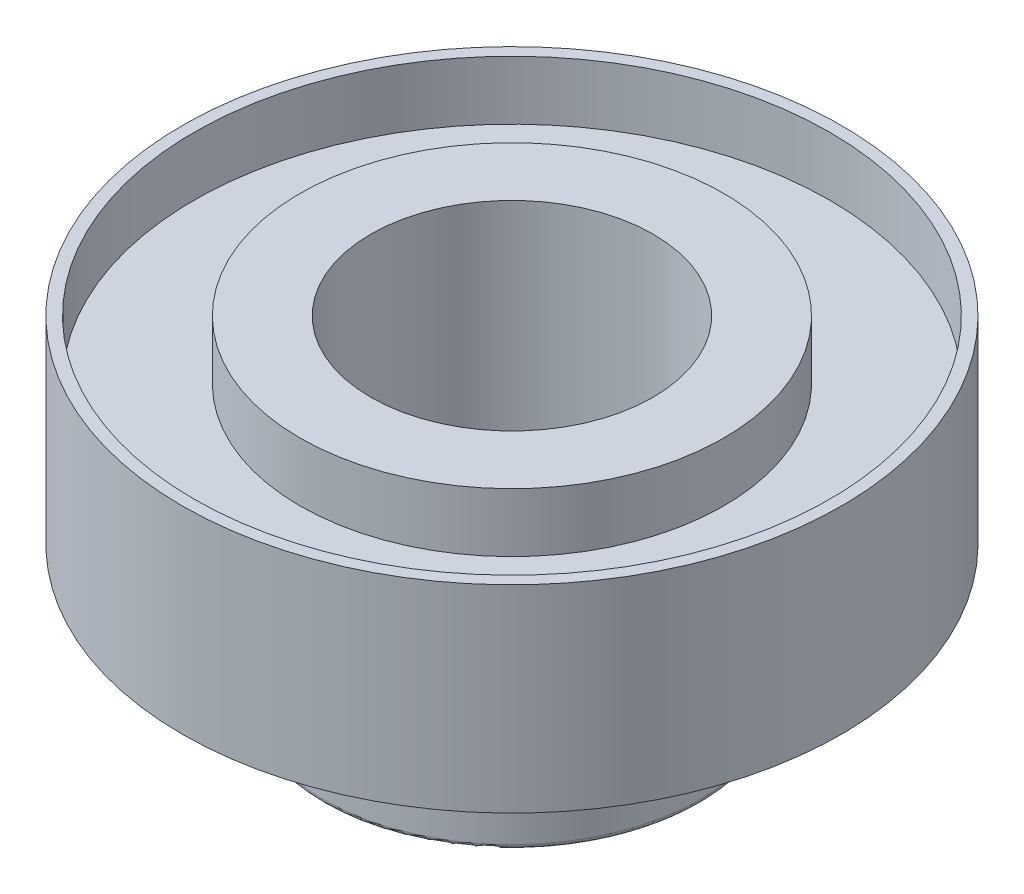
from build123d import *

# Parameters (mm, degrees)
SKETCH1_R           = 7
BOSS_EXTRUDE1_DEPTH = 4.2
SKETCH2_R           = 3
CUT_EXTRUDE1_DEPTH  = 4.2
SKETCH3_R           = 6.75
SKETCH3_R_2         = 4.5
CUT_EXTRUDE2_DEPTH  = 1.25
SKETCH4_R           = 4
SKETCH4_R_2         = 3
BOSS_EXTRUDE2_DEPTH = 2.8
FILLET1_R           = 0.1


with BuildPart() as part:
    # Sketch1 → Boss-Extrude1 (new body)
    with BuildSketch(Plane(origin=(0, 0, 0), x_dir=(1, 0, 0), z_dir=(0, 1, 0))):
        Circle(SKETCH1_R)
    extrude(amount=BOSS_EXTRUDE1_DEPTH)

    # Sketch2 → Cut-Extrude1 (cut)
    with BuildSketch(Plane(origin=(0, 4.2, 0), x_dir=(1, 0, 0), z_dir=(0, 1, 0))):
        Circle(SKETCH2_R)
    extrude(amount=-CUT_EXTRUDE1_DEPTH, mode=Mode.SUBTRACT)

    # Sketch3 → Cut-Extrude2 (cut)
    with BuildSketch(Plane(origin=(0, 4.2, 0), x_dir=(1, 0, 0), z_dir=(0, 1, 0))):
        Circle(SKETCH3_R)
        Circle(SKETCH3_R_2, mode=Mode.SUBTRACT)
    extrude(amount=-CUT_EXTRUDE2_DEPTH, mode=Mode.SUBTRACT)

    # Sketch4 → Boss-Extrude2 (add)
    with BuildSketch(Plane.XZ):
        Circle(SKETCH4_R)
        Circle(SKETCH4_R_2, mode=Mode.SUBTRACT)
    extrude(amount=BOSS_EXTRUDE2_DEPTH)

    # Fillet1
    fillet1_edges = [part.edges().sort_by_distance(p)[0] for p in [
        (-4, -2.8, 0),
    ]]
    fillet(fillet1_edges, radius=FILLET1_R)


solid = part.part
